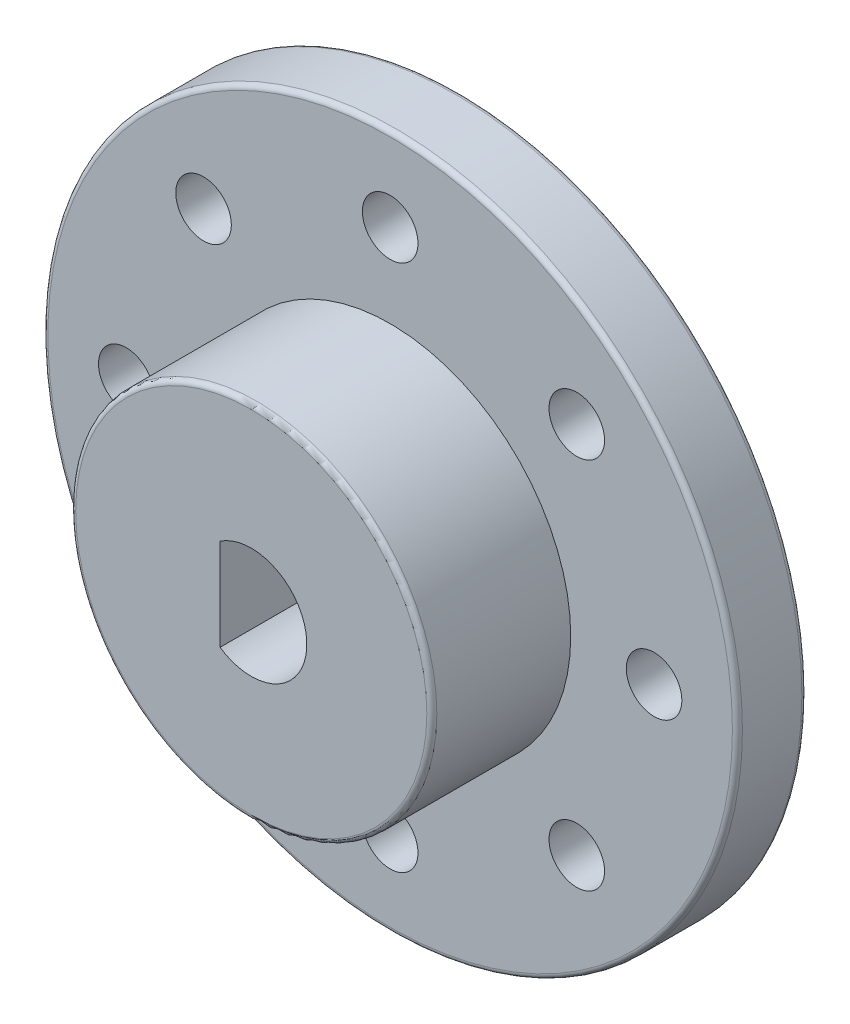
from build123d import *

# Parameters (mm, degrees)
SKETCH_1_R          = 25
SKETCH_1_R_2        = 4
EXTRUDE_1_DEPTH     = 5
EXTRUDE_2_DEPTH     = 5
SKETCH_5_R          = 13
EXTRUDE_3_DEPTH     = 10
CUT_EXTRUDE_1_DEPTH = 18
SKETCH_7_R          = 2
CUT_EXTRUDE_2_DEPTH = 18
FILLET_4_R          = 0.36


with BuildPart() as part:
    # 草图1 → 凸台-拉伸1 (new body)
    with BuildSketch(Plane.XY):
        Circle(SKETCH_1_R)
        Circle(SKETCH_1_R_2, mode=Mode.SUBTRACT)
    extrude(amount=EXTRUDE_1_DEPTH)

    # 草图2 → 凸台-拉伸2 (add)
    with BuildSketch(Plane.XY.offset(5)):
        with BuildLine():
            Line((-2.247476495, -3.308904563), (-2.247476495, 3.308904563))
            ThreePointArc((-2.247476495, 3.308904563), (-4, 0), (-2.247476495, -3.308904563))
        make_face()
    extrude(amount=-EXTRUDE_2_DEPTH)

    # 草图5 → 凸台-拉伸3 (add)
    with BuildSketch(Plane.XY.offset(5)):
        Circle(SKETCH_5_R)
    extrude(amount=EXTRUDE_3_DEPTH)

    # 草图6 → 切除-拉伸1 (cut)
    with BuildSketch(Plane(origin=(0, 0, 0), x_dir=(-1, 0, 0), z_dir=(0, 0, -1))):
        with BuildLine():
            Line((2.247476495, 3.308904563), (2.247476495, -3.308904563))
            ThreePointArc((2.247476495, -3.308904563), (-4, 0), (2.247476495, 3.308904563))
        make_face()
    extrude(amount=-CUT_EXTRUDE_1_DEPTH, mode=Mode.SUBTRACT)

    # 草图7 → 切除-拉伸2 (cut)
    with BuildSketch(Plane.XY.offset(5)):
        with Locations((0, 19)):
            Circle(SKETCH_7_R)
        with Locations((13.435028843, 13.435028843)):
            Circle(SKETCH_7_R)
        with Locations((19, 0)):
            Circle(SKETCH_7_R)
        with Locations((13.435028843, -13.435028843)):
            Circle(SKETCH_7_R)
        with Locations((0, -19)):
            Circle(SKETCH_7_R)
        with Locations((-13.435028843, -13.435028843)):
            Circle(SKETCH_7_R)
        with Locations((-19, 0)):
            Circle(SKETCH_7_R)
        with Locations((-13.435028843, 13.435028843)):
            Circle(SKETCH_7_R)
    extrude(amount=-CUT_EXTRUDE_2_DEPTH, mode=Mode.SUBTRACT)

    # 圆角4
    fillet_4_edges = [part.edges().sort_by_distance(p)[0] for p in [
        (-25, 0, 0),
        (-13, 0, 15),
        (-25, 0, 5),
    ]]
    fillet(fillet_4_edges, radius=FILLET_4_R)


solid = part.part
